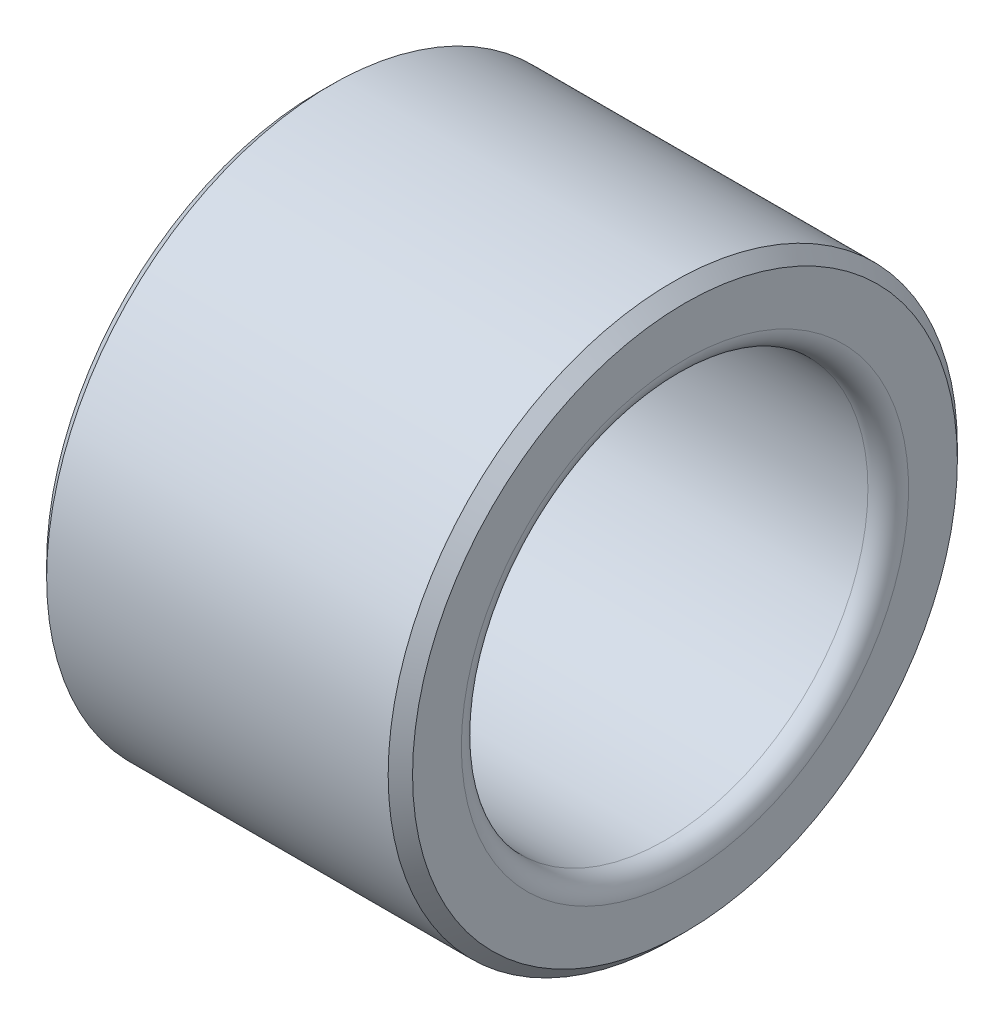
from build123d import *

# Parameters (mm, degrees)
SKETCH_1_W     = 9
SKETCH_1_H     = 2
CHAMFER_1_SIZE = 0.3
FILLET_1_R     = 0.5


with BuildPart() as part:
    # 草圖1 → 旋轉1 (revolve)
    with BuildSketch(Plane.XY):
        with Locations((0, 6)):
            Rectangle(SKETCH_1_W, SKETCH_1_H)
    revolve(axis=Axis((-51.523727229, 0, 0), (1, 0, 0)))

    # 導角1
    chamfer_1_edges = [part.edges().sort_by_distance(p)[0] for p in [
        (4.5, -7, 0),
        (-4.5, -7, 0),
    ]]
    chamfer(chamfer_1_edges, length=CHAMFER_1_SIZE)

    # 圓角1
    fillet_1_edges = [part.edges().sort_by_distance(p)[0] for p in [
        (-4.5, -5, 0),
        (4.5, -5, 0),
    ]]
    fillet(fillet_1_edges, radius=FILLET_1_R)


solid = part.part
